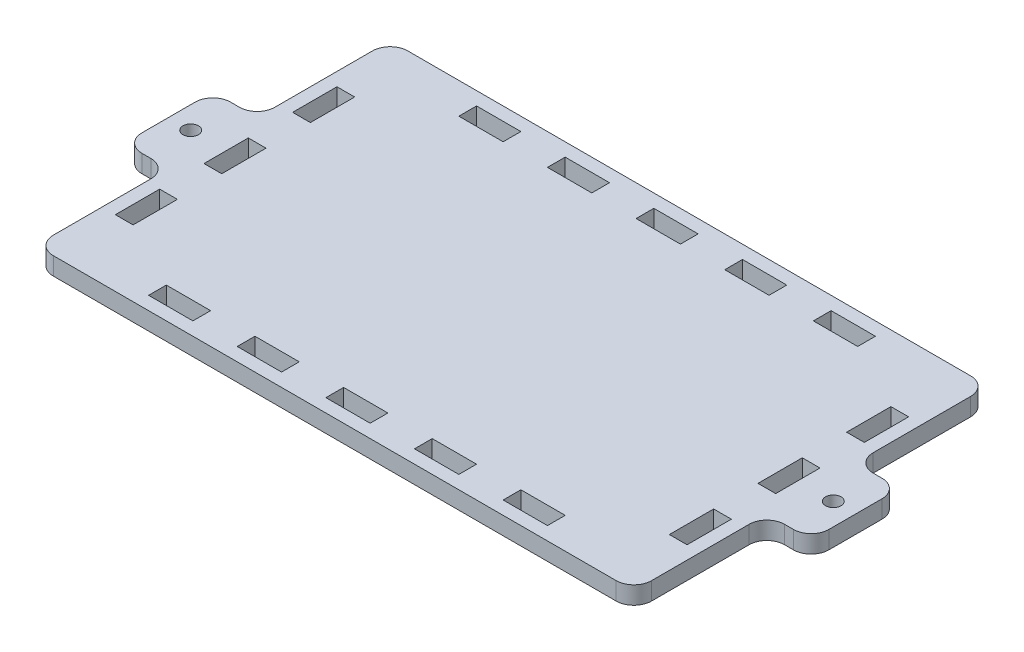
from build123d import *

# Parameters (mm, degrees)
SKETCH1_W           = 129
SKETCH1_H           = 74
BOSS_EXTRUDE1_DEPTH = 4
SKETCH4_W           = 4
SKETCH4_H           = 10
SKETCH4_W_2         = 10
SKETCH4_H_2         = 4
CUT_EXTRUDE3_DEPTH  = 5
SKETCH5_W           = 135
SKETCH5_H           = 80
SKETCH5_W_2         = 129
SKETCH5_H_2         = 74
BOSS_EXTRUDE2_DEPTH = 4
SKETCH6_W           = 10
SKETCH6_H           = 20
SKETCH6_R           = 1.75
BOSS_EXTRUDE3_DEPTH = 4
FILLET1_R           = 4


with BuildPart() as part:
    # Sketch1 → Boss-Extrude1 (new body)
    with BuildSketch(Plane(origin=(0, 0, 0), x_dir=(1, 0, 0), z_dir=(0, 1, 0))):
        with Locations((64.5, -37)):
            Rectangle(SKETCH1_W, SKETCH1_H)
    extrude(amount=BOSS_EXTRUDE1_DEPTH)

    # Sketch4 → Cut-Extrude3 (cut, through all)
    with BuildSketch(Plane(origin=(0, 4, 0), x_dir=(1, 0, 0), z_dir=(0, 1, 0))):
        with Locations((127, -57)):
            Rectangle(SKETCH4_W, SKETCH4_H)
        with Locations((127, -37)):
            Rectangle(SKETCH4_W, SKETCH4_H)
        with Locations((127, -17)):
            Rectangle(SKETCH4_W, SKETCH4_H)
        with Locations((2, -57)):
            Rectangle(SKETCH4_W, SKETCH4_H)
        with Locations((2, -37)):
            Rectangle(SKETCH4_W, SKETCH4_H)
        with Locations((2, -17)):
            Rectangle(SKETCH4_W, SKETCH4_H)
        with Locations((104.5, -2)):
            Rectangle(SKETCH4_W_2, SKETCH4_H_2)
        with Locations((84.5, -2)):
            Rectangle(SKETCH4_W_2, SKETCH4_H_2)
        with Locations((64.5, -2)):
            Rectangle(SKETCH4_W_2, SKETCH4_H_2)
        with Locations((44.5, -2)):
            Rectangle(SKETCH4_W_2, SKETCH4_H_2)
        with Locations((24.5, -2)):
            Rectangle(SKETCH4_W_2, SKETCH4_H_2)
        with Locations((104.5, -72)):
            Rectangle(SKETCH4_W_2, SKETCH4_H_2)
        with Locations((84.5, -72)):
            Rectangle(SKETCH4_W_2, SKETCH4_H_2)
        with Locations((64.5, -72)):
            Rectangle(SKETCH4_W_2, SKETCH4_H_2)
        with Locations((44.5, -72)):
            Rectangle(SKETCH4_W_2, SKETCH4_H_2)
        with Locations((24.5, -72)):
            Rectangle(SKETCH4_W_2, SKETCH4_H_2)
    extrude(amount=-CUT_EXTRUDE3_DEPTH, mode=Mode.SUBTRACT)

    # Sketch5 → Boss-Extrude2 (add, through all)
    with BuildSketch(Plane(origin=(0, 4, 0), x_dir=(1, 0, 0), z_dir=(0, 1, 0))):
        with Locations((64.5, -37)):
            Rectangle(SKETCH5_W, SKETCH5_H)
        with Locations((64.5, -37)):
            Rectangle(SKETCH5_W_2, SKETCH5_H_2, mode=Mode.SUBTRACT)
    extrude(amount=-BOSS_EXTRUDE2_DEPTH)

    # Sketch6 → Boss-Extrude3 (add, through all)
    with BuildSketch(Plane.XZ):
        with Locations((137, 37)):
            Rectangle(SKETCH6_W, SKETCH6_H)
        with Locations((137, 37)):
            Circle(SKETCH6_R, mode=Mode.SUBTRACT)
        with Locations((-8, 37)):
            Rectangle(SKETCH6_W, SKETCH6_H)
        with Locations((-8, 37)):
            Circle(SKETCH6_R, mode=Mode.SUBTRACT)
    extrude(amount=-BOSS_EXTRUDE3_DEPTH)

    # Fillet1
    fillet1_edges = [part.edges().sort_by_distance(p)[0] for p in [
        (132, 2, -3),
        (132, 2, 77),
        (-3, 2, 77),
        (-3, 2, -3),
        (132, 2, 27),
        (132, 2, 47),
        (142, 2, 47),
        (142, 2, 27),
        (-13, 2, 27),
        (-13, 2, 47),
        (-3, 2, 47),
        (-3, 2, 27),
    ]]
    fillet(fillet1_edges, radius=FILLET1_R)


solid = part.part
